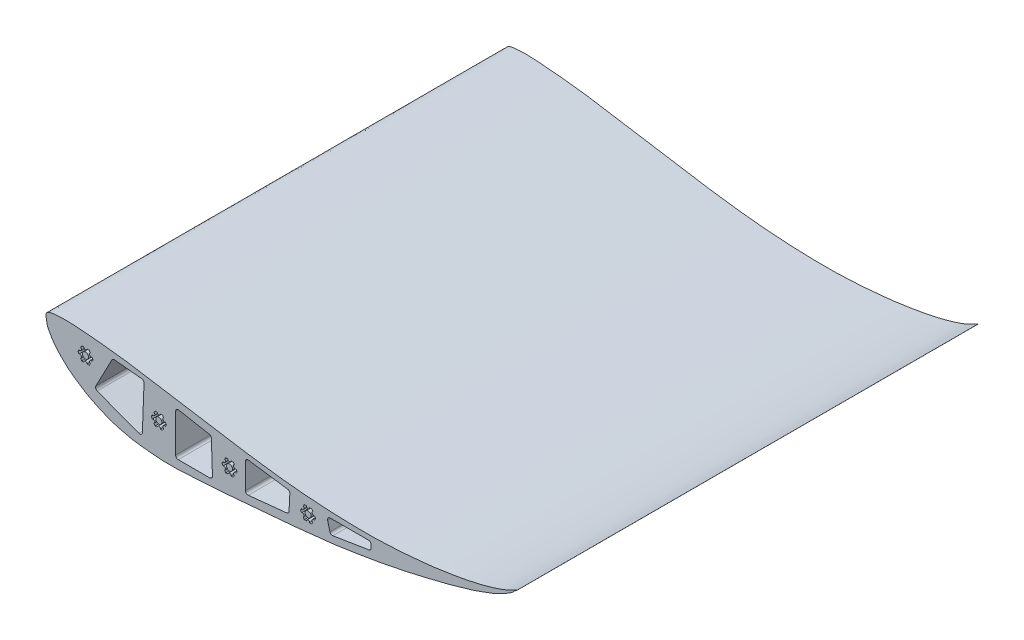
from build123d import *

# Parameters (mm, degrees)
BOSS_EXTRUDE1_DEPTH = 446.6166582
SKETCH4_R           = 2.9337
CUT_EXTRUDE3_DEPTH  = 381


with BuildPart() as part:
    # Sketch1 → Boss-Extrude1 (new body)
    with BuildSketch(Plane.XY):
        with BuildLine():
            add(Edge.make_bspline(
                [(-16.622525288, 91.56967272), (-16.794942994, 92.772317911), (-17.515788121, 97.582670832), (-2.852582554, 99.497127174), (9.154054709, 99.213304724), (23.433217875, 97.797752429), (34.6859051, 97.019819773), (46.592767258, 95.707761604), (58.472171701, 94.254609297), (72.666253463, 92.219697635), (88.15460255, 89.685431784), (109.15740223, 86.162485471), (130.076144789, 82.711728928), (150.055716296, 79.576696099), (168.256858053, 76.617688262), (186.559493812, 73.857794613), (206.695059336, 71.20791695), (225.195546149, 69.114961125), (244.068606399, 67.656695297), (262.594452449, 66.476567979), (282.222526995, 65.926744761), (300.99609332, 65.813021246), (318.737894065, 66.539084176), (334.742865336, 67.61277327), (348.252438633, 69.009944705), (359.067906447, 70.049570339), (367.896874578, 71.420704301), (377.007425502, 72.883057797), (386.227823421, 74.138373924), (395.367743176, 76.385575861), (403.564697097, 77.907582397), (410.735250399, 79.953005658), (417.114285798, 81.687412008), (422.732680223, 83.591992804), (427.164087313, 85.094079009), (431.171696898, 86.937153076), (434.607250511, 88.392786361), (443.123217376, 93.275688905), (437.255094337, 89.117703468), (435.279778464, 86.561175616), (431.573501891, 84.704524529), (428.464842726, 82.201032813), (424.134266462, 80.398696308), (419.425258521, 77.797857577), (414.105440345, 75.713007702), (408.77839072, 73.798734141), (403.684867312, 72.029145889), (396.961540144, 69.466067962), (387.343622202, 67.136732033), (376.830663922, 63.608926675), (365.24798357, 60.901656463), (354.754672426, 58.255886458), (344.650791699, 55.720154361), (336.670341174, 53.941801639), (329.235250959, 52.381752299), (321.327868225, 50.676833739), (310.892392252, 48.725728026), (298.426712372, 46.308387166), (284.136528131, 44.189578856), (268.909448728, 41.574011521), (251.075314715, 39.596728872), (229.386892765, 37.203012777), (203.753382466, 34.933554815), (177.46976253, 32.720447696), (150.443659112, 30.344574846), (123.02307167, 28.688327838), (101.004781565, 27.555963663), (84.804305156, 28.931500406), (75.72348416, 30.010523718), (67.270753352, 30.977463397), (60.250592801, 32.582425676), (53.932519662, 34.232006507), (47.114759922, 36.133551764), (41.43120503, 38.368275103), (36.428795002, 40.445297648), (32.069577899, 42.402430324), (27.662403595, 44.667790264), (23.104788958, 46.965799851), (18.73168781, 49.734821084), (12.723675127, 53.669846892), (5.809434759, 58.404883079), (-1.037305312, 65.077409289), (-6.513200759, 70.614178991), (-10.540658158, 76.008047875), (-12.880350205, 80.406543609), (-15.167480815, 84.128221175), (-16.123087236, 87.961419413), (-16.453570873, 90.391184614), (-16.622525288, 91.56967272)],
                knots=[0, 0, 0, 0, 0.003644297, 0.013581344, 0.034074787, 0.047557163, 0.057150579, 0.06958931, 0.084962672, 0.094623108, 0.114452008, 0.134073068, 0.161263036, 0.180794832, 0.197357561, 0.218965716, 0.238711125, 0.26090768, 0.277214827, 0.297940316, 0.318988728, 0.338651177, 0.356673355, 0.374539934, 0.388835783, 0.399172974, 0.408530924, 0.416784345, 0.428053881, 0.437617365, 0.446213781, 0.454125754, 0.460928052, 0.466918155, 0.472615005, 0.475771621, 0.480179638, 0.487250343, 0.490988881, 0.49507496, 0.498775568, 0.503369536, 0.507624299, 0.513322415, 0.520215853, 0.525455504, 0.531043662, 0.537088919, 0.5479516, 0.561953721, 0.571760074, 0.585151118, 0.595822817, 0.604354359, 0.61073386, 0.619595652, 0.629664863, 0.643953388, 0.659323518, 0.674864947, 0.692287919, 0.715453133, 0.743149301, 0.772805526, 0.797998576, 0.828023399, 0.858832685, 0.866768477, 0.87886578, 0.88746214, 0.893357873, 0.901377327, 0.907903322, 0.915486693, 0.920464298, 0.924856032, 0.930432876, 0.935970498, 0.940815755, 0.946613865, 0.958462559, 0.966932993, 0.97647901, 0.982815006, 0.98789669, 0.992067686, 0.996428904, 1, 1, 1, 1], degree=3))
        make_face()
    extrude(amount=BOSS_EXTRUDE1_DEPTH)

    # Sketch4 → Cut-Extrude3 (cut)
    with BuildSketch(Plane.XY.offset(446.6166582)):
        with BuildLine():
            Line((88.931300118, 66.243537573), (91.009974327, 66.243537573))
            ThreePointArc((91.009974327, 66.243537573), (92.597474327, 64.656037573), (94.184974327, 66.243537573))
            Line((94.184974327, 66.243537573), (96.263648536, 66.243537573))
            Line((96.263648536, 66.243537573), (97.302985641, 64.443352902))
            ThreePointArc((97.302985641, 64.443352902), (96.721920503, 62.274787243), (98.890486301, 61.693722626))
            Line((98.890486301, 61.693722626), (99.929823515, 59.893537766))
            Line((99.929823515, 59.893537766), (98.89048641, 58.093353094))
            ThreePointArc((98.89048641, 58.093353094), (96.721921082, 57.512287766), (97.30298641, 55.343722437))
            Line((97.30298641, 55.343722437), (96.263649306, 53.543537766))
            Line((96.263649306, 53.543537766), (94.184975096, 53.543537766))
            ThreePointArc((94.184975096, 53.543537766), (92.597475, 55.131037573), (91.009975096, 53.543537573))
            Line((91.009975096, 53.543537573), (88.931300887, 53.543537573))
            Line((88.931300887, 53.543537573), (87.891963673, 55.343722182))
            ThreePointArc((87.891963673, 55.343722182), (88.47302887, 57.512287545), (86.304463507, 58.093352743))
            Line((86.304463507, 58.093352743), (85.265126293, 59.893537351))
            Line((85.265126293, 59.893537351), (86.304463288, 61.693722086))
            ThreePointArc((86.304463288, 61.693722086), (88.473028582, 62.274787545), (87.891963122, 64.443352839))
            Line((87.891963122, 64.443352839), (88.931300118, 66.243537573))
        make_face()
        with Locations((92.597474712, 59.893537795)):
            Circle(SKETCH4_R, mode=Mode.SUBTRACT)
        with BuildLine():
            Line((17.811300118, 85.293537573), (19.889974327, 85.293537573))
            ThreePointArc((19.889974327, 85.293537573), (21.477474327, 83.706037573), (23.064974327, 85.293537573))
            Line((23.064974327, 85.293537573), (25.143648536, 85.293537573))
            Line((25.143648536, 85.293537573), (26.182985641, 83.493352902))
            ThreePointArc((26.182985641, 83.493352902), (25.601920503, 81.324787243), (27.770486301, 80.743722626))
            Line((27.770486301, 80.743722626), (28.809823515, 78.943537766))
            Line((28.809823515, 78.943537766), (27.77048641, 77.143353094))
            ThreePointArc((27.77048641, 77.143353094), (25.601921082, 76.562287766), (26.18298641, 74.393722437))
            Line((26.18298641, 74.393722437), (25.143649306, 72.593537766))
            Line((25.143649306, 72.593537766), (23.064975096, 72.593537766))
            ThreePointArc((23.064975096, 72.593537766), (21.477475, 74.181037573), (19.889975096, 72.593537573))
            Line((19.889975096, 72.593537573), (17.811300887, 72.593537573))
            Line((17.811300887, 72.593537573), (16.771963673, 74.393722182))
            ThreePointArc((16.771963673, 74.393722182), (17.35302887, 76.562287545), (15.184463507, 77.143352743))
            Line((15.184463507, 77.143352743), (14.145126293, 78.943537351))
            Line((14.145126293, 78.943537351), (15.184463288, 80.743722086))
            ThreePointArc((15.184463288, 80.743722086), (17.353028582, 81.324787545), (16.771963122, 83.493352839))
            Line((16.771963122, 83.493352839), (17.811300118, 85.293537573))
        make_face()
        with Locations((21.477474712, 78.943537795)):
            Circle(SKETCH4_R, mode=Mode.SUBTRACT)
        with BuildLine():
            Line((233.711300118, 59.893537573), (235.789974327, 59.893537573))
            ThreePointArc((235.789974327, 59.893537573), (237.377474327, 58.306037573), (238.964974327, 59.893537573))
            Line((238.964974327, 59.893537573), (241.043648536, 59.893537573))
            Line((241.043648536, 59.893537573), (242.082985641, 58.093352902))
            ThreePointArc((242.082985641, 58.093352902), (241.501920503, 55.924787243), (243.670486301, 55.343722626))
            Line((243.670486301, 55.343722626), (244.709823515, 53.543537766))
            Line((244.709823515, 53.543537766), (243.67048641, 51.743353094))
            ThreePointArc((243.67048641, 51.743353094), (241.501921082, 51.162287766), (242.08298641, 48.993722437))
            Line((242.08298641, 48.993722437), (241.043649306, 47.193537766))
            Line((241.043649306, 47.193537766), (238.964975096, 47.193537766))
            ThreePointArc((238.964975096, 47.193537766), (237.377475, 48.781037573), (235.789975096, 47.193537573))
            Line((235.789975096, 47.193537573), (233.711300887, 47.193537573))
            Line((233.711300887, 47.193537573), (232.671963673, 48.993722182))
            ThreePointArc((232.671963673, 48.993722182), (233.25302887, 51.162287545), (231.084463507, 51.743352743))
            Line((231.084463507, 51.743352743), (230.045126293, 53.543537351))
            Line((230.045126293, 53.543537351), (231.084463288, 55.343722086))
            ThreePointArc((231.084463288, 55.343722086), (233.253028582, 55.924787545), (232.671963122, 58.093352839))
            Line((232.671963122, 58.093352839), (233.711300118, 59.893537573))
        make_face()
        with Locations((237.377474712, 53.543537795)):
            Circle(SKETCH4_R, mode=Mode.SUBTRACT)
        with BuildLine():
            Line((157.511300118, 61.163537573), (159.589974327, 61.163537573))
            ThreePointArc((159.589974327, 61.163537573), (161.177474327, 59.576037573), (162.764974327, 61.163537573))
            Line((162.764974327, 61.163537573), (164.843648536, 61.163537573))
            Line((164.843648536, 61.163537573), (165.882985641, 59.363352902))
            ThreePointArc((165.882985641, 59.363352902), (165.301920503, 57.194787243), (167.470486301, 56.613722626))
            Line((167.470486301, 56.613722626), (168.509823515, 54.813537766))
            Line((168.509823515, 54.813537766), (167.47048641, 53.013353094))
            ThreePointArc((167.47048641, 53.013353094), (165.301921082, 52.432287766), (165.88298641, 50.263722437))
            Line((165.88298641, 50.263722437), (164.843649306, 48.463537766))
            Line((164.843649306, 48.463537766), (162.764975096, 48.463537766))
            ThreePointArc((162.764975096, 48.463537766), (161.177475, 50.051037573), (159.589975096, 48.463537573))
            Line((159.589975096, 48.463537573), (157.511300887, 48.463537573))
            Line((157.511300887, 48.463537573), (156.471963673, 50.263722182))
            ThreePointArc((156.471963673, 50.263722182), (157.05302887, 52.432287545), (154.884463507, 53.013352743))
            Line((154.884463507, 53.013352743), (153.845126293, 54.813537351))
            Line((153.845126293, 54.813537351), (154.884463288, 56.613722086))
            ThreePointArc((154.884463288, 56.613722086), (157.053028582, 57.194787545), (156.471963122, 59.363352839))
            Line((156.471963122, 59.363352839), (157.511300118, 61.163537573))
        make_face()
        with Locations((161.177474712, 54.813537795)):
            Circle(SKETCH4_R, mode=Mode.SUBTRACT)
        with BuildLine():
            Line((31.501207482, 58.37669779), (47.032113751, 88.081016492))
            ThreePointArc((47.032113751, 88.081016492), (48.076445172, 89.139261035), (49.534182489, 89.431684603))
            Line((49.534182489, 89.431684603), (75.93058222, 86.808602351))
            ThreePointArc((75.93058222, 86.808602351), (77.593752589, 85.950453195), (78.217633108, 84.185990458))
            Line((78.217633108, 84.185990458), (76.631821885, 41.843273018))
            ThreePointArc((76.631821885, 41.843273018), (75.497981954, 39.821894696), (73.194863199, 39.56265096))
            Line((73.194863199, 39.56265096), (32.853368422, 54.824131949))
            ThreePointArc((32.853368422, 54.824131949), (31.378241648, 56.296285615), (31.501207482, 58.37669779))
        make_face()
        with BuildLine():
            Line((111.858309541, 78.393902518), (141.485442222, 72.962296795))
            ThreePointArc((141.485442222, 72.962296795), (142.950940478, 72.12274223), (143.565962065, 70.549756072))
            Line((143.565962065, 70.549756072), (144.628770085, 39.112135773))
            ThreePointArc((144.628770085, 39.112135773), (143.916361615, 37.260866924), (142.090220332, 36.486315313))
            Line((142.090220332, 36.486315313), (111.400279631, 36.486315313))
            ThreePointArc((111.400279631, 36.486315313), (109.604228407, 37.230264089), (108.860279631, 39.026315313))
            Line((108.860279631, 39.026315313), (108.860279631, 75.895541334))
            ThreePointArc((108.860279631, 75.895541334), (109.774210132, 77.846822448), (111.858309541, 78.393902518))
        make_face()
        with BuildLine():
            Line((179.473393864, 70.165192722), (217.50482476, 64.769576264))
            ThreePointArc((217.50482476, 64.769576264), (219.108331349, 63.86995645), (219.68467301, 62.123995546))
            Line((219.68467301, 62.123995546), (218.890378913, 46.71578744))
            ThreePointArc((218.890378913, 46.71578744), (218.192789678, 45.094545708), (216.607247121, 44.319232678))
            Line((216.607247121, 44.319232678), (179.370110323, 40.58420072))
            ThreePointArc((179.370110323, 40.58420072), (177.412540188, 41.227973149), (176.576610312, 43.111519011))
            Line((176.576610312, 43.111519011), (176.576610312, 67.650375533))
            ThreePointArc((176.576610312, 67.650375533), (177.451472213, 69.568425352), (179.473393864, 70.165192722))
        make_face()
        with BuildLine():
            Line((258.751236774, 61.163537573), (296.003687002, 61.163537573))
            ThreePointArc((296.003687002, 61.163537573), (297.799738226, 60.419588797), (298.543687002, 58.623537573))
            Line((298.543687002, 58.623537573), (298.543687002, 55.707363059))
            ThreePointArc((298.543687002, 55.707363059), (297.937199117, 54.060204626), (296.407363457, 53.199645906))
            Line((296.407363457, 53.199645906), (261.377375447, 47.560739881))
            ThreePointArc((261.377375447, 47.560739881), (259.584877656, 47.941775277), (258.515299797, 49.429807368))
            Line((258.515299797, 49.429807368), (256.292837579, 57.984887907))
            ThreePointArc((256.292837579, 57.984887907), (256.742036666, 60.177472876), (258.751236774, 61.163537573))
        make_face()
    extrude(amount=-CUT_EXTRUDE3_DEPTH, mode=Mode.SUBTRACT)


solid = part.part
